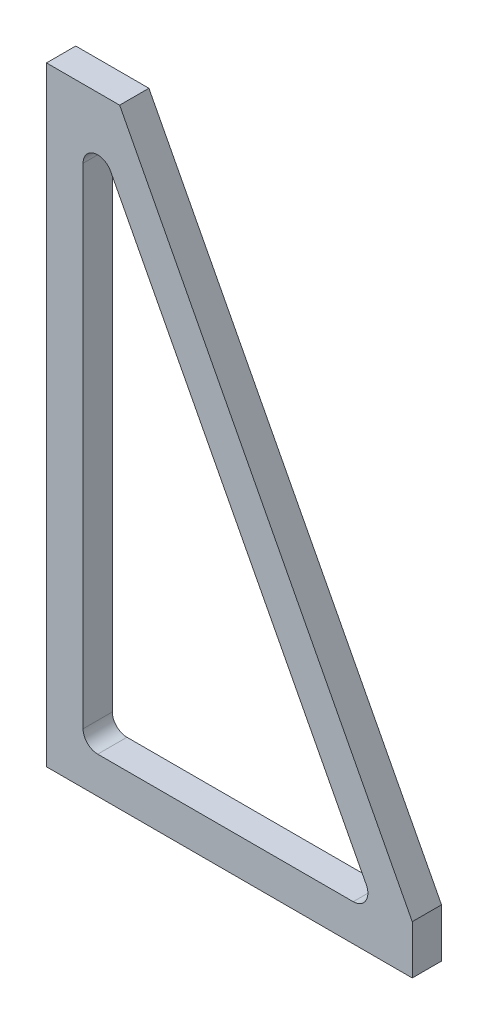
from build123d import *

# Parameters (mm, degrees)
BOSS_EXTRUDE1_DEPTH = 12


with BuildPart() as part:
    # Sketch1 → Boss-Extrude1 (new body)
    with BuildSketch(Plane.XY):
        Polygon((150, 0), (0, 0), (0, 250), (30, 250), (150, 20), align=None)
        with BuildLine():
            Line((26.319509077, 224.626469841), (131.111373669, 23.77539604))
            ThreePointArc((131.111373669, 23.77539604), (130.922769787, 17.88972479), (125.791864592, 15))
            Line((125.791864592, 15), (21, 15))
            ThreePointArc((21, 15), (16.757359313, 16.757359313), (15, 21))
            Line((15, 21), (15, 221.851073801))
            ThreePointArc((15, 221.851073801), (19.571198835, 227.67846835), (26.319509077, 224.626469841))
        make_face(mode=Mode.SUBTRACT)
    extrude(amount=BOSS_EXTRUDE1_DEPTH)


solid = part.part
